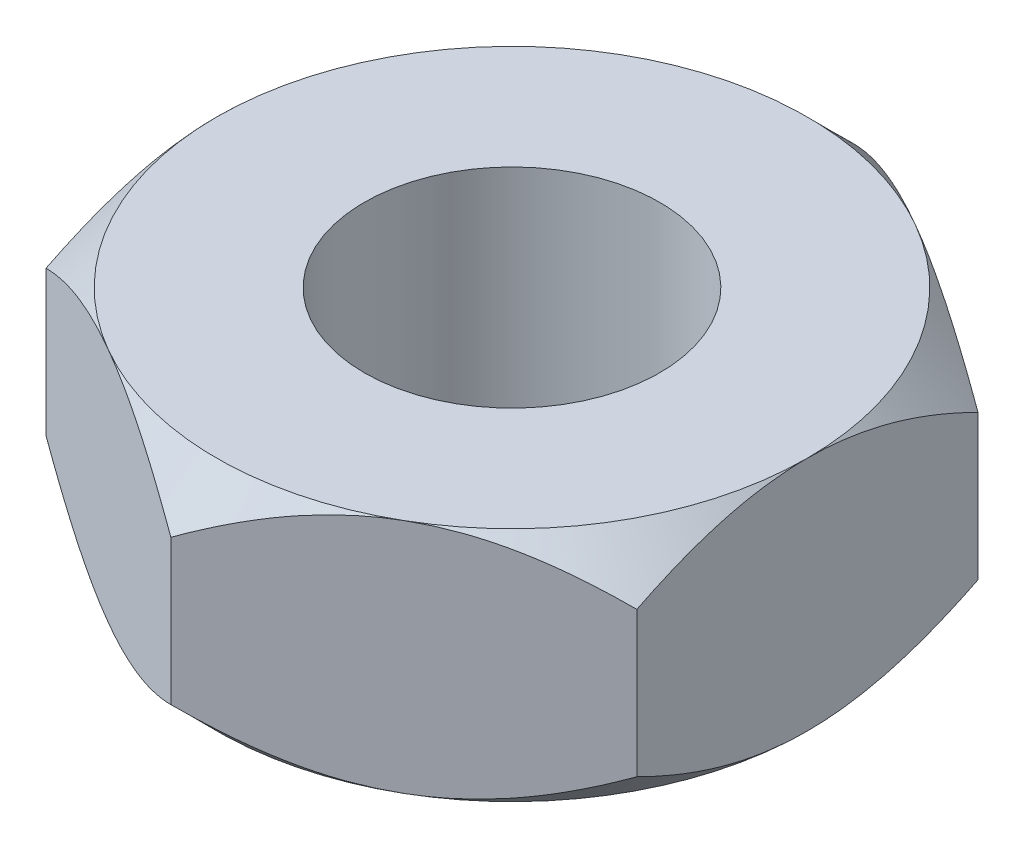
from build123d import *

# Parameters (mm, degrees)
SKETCH1_R           = 1.25
BOSS_EXTRUDE1_DEPTH = 2
SKETCH2_OUTSIDE_W   = 14.58
SKETCH2_OUTSIDE_H   = 15.354
SKETCH2_OUTSIDE_R   = 2.5
CUT_EXTRUDE1_DEPTH  = 3
CUT_EXTRUDE1_TAPER  = 45
SKETCH3_OUTSIDE_W   = 14.58
SKETCH3_OUTSIDE_H   = 15.354
SKETCH3_OUTSIDE_R   = 2.5
CUT_EXTRUDE2_DEPTH  = 3
CUT_EXTRUDE2_TAPER  = 45


with BuildPart() as part:
    # Sketch1 → Boss-Extrude1 (new body)
    with BuildSketch(Plane(origin=(0, 0, 0), x_dir=(1, 0, 0), z_dir=(0, 1, 0))):
        Polygon((0, 2.886751346), (-2.5, 1.443375673), (-2.5, -1.443375673), (0, -2.886751346), (2.5, -1.443375673), (2.5, 1.443375673), align=None)
        Circle(SKETCH1_R, mode=Mode.SUBTRACT)
    extrude(amount=BOSS_EXTRUDE1_DEPTH)

    # Sketch2 outside → Cut-Extrude1 (cut, through all)
    with BuildSketch(Plane(origin=(0, 2, 0), x_dir=(1, 0, 0), z_dir=(0, 1, 0))):
        Rectangle(SKETCH2_OUTSIDE_W, SKETCH2_OUTSIDE_H)
        Circle(SKETCH2_OUTSIDE_R, mode=Mode.SUBTRACT)
    extrude(amount=-CUT_EXTRUDE1_DEPTH, taper=CUT_EXTRUDE1_TAPER, mode=Mode.SUBTRACT)

    # Sketch3 outside → Cut-Extrude2 (cut, through all)
    with BuildSketch(Plane.XZ):
        Rectangle(SKETCH3_OUTSIDE_W, SKETCH3_OUTSIDE_H)
        Circle(SKETCH3_OUTSIDE_R, mode=Mode.SUBTRACT)
    extrude(amount=-CUT_EXTRUDE2_DEPTH, taper=CUT_EXTRUDE2_TAPER, mode=Mode.SUBTRACT)


solid = part.part
